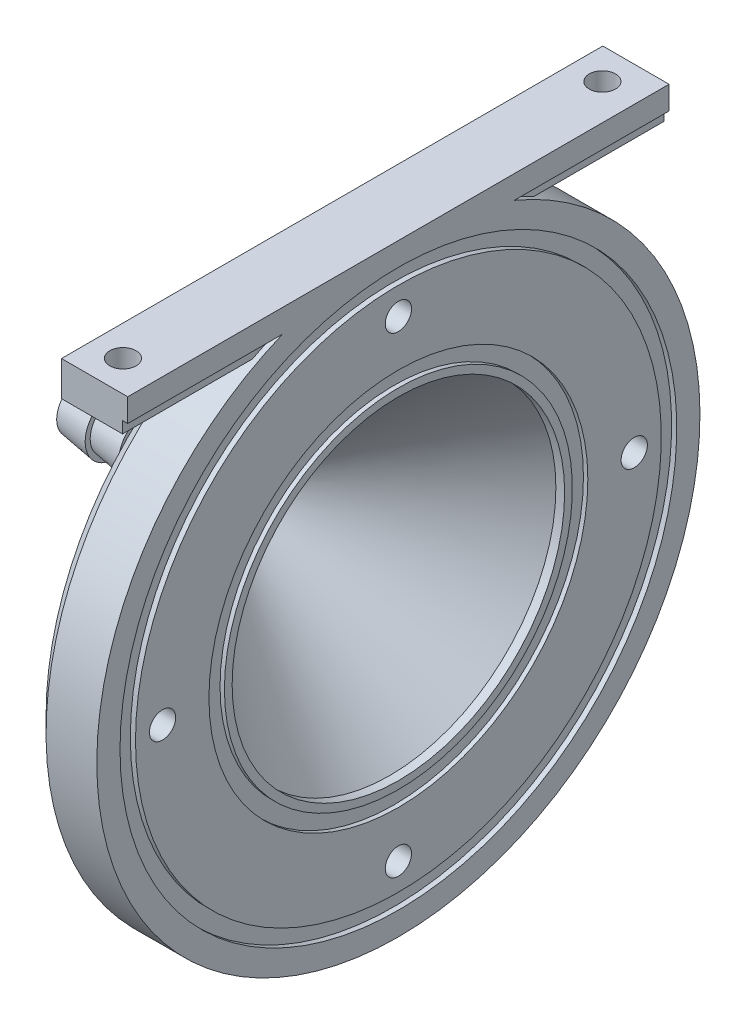
from build123d import *

# Parameters (mm, degrees)
SKETCH1_W                = 0.566
SKETCH1_H                = 1
M3_CLEARANCE_HOLE1_D     = 3.4
M3_CLEARANCE_HOLE1_DEPTH = 8.566
M3_CLEARANCE_HOLE1_TIP   = 1.021463052
CHAMFER1_SIZE            = 2
BOSS_EXTRUDE1_DEPTH      = 35
SKETCH9_R                = 1.7
CUT_EXTRUDE1_DEPTH       = 10


with BuildPart() as part:
    # Sketch1 → Revolve17 (revolve)
    with BuildSketch(Plane.XY, mode=Mode.PRIVATE) as revolve17_sk:
        Polygon((14.13111535, 39), (14.13111535, 34.5), (22.03011535, 34.5), (22.03011535, 36), (22.69711535, 36), (22.69711535, 39), align=None)
        Polygon((-14.010170791, 3.15), (-14.010170791, 3.8), (-18.343504124, 3.15), (-18.343504124, 1.9), (0, 1.9), (21.56511535, 21.5), (22.13111535, 21.5), (22.13111535, 22.5), (22.13111535, 24.5), (22.69711535, 24.5), (22.69711535, 34), (22.03011535, 34), (22.03011535, 34.5), (14.13111535, 34.5), (14.13111535, 21.5), (-5.343504124, 3.8), (-9.676837458, 3.15), (-9.676837458, 3.8), align=None)
        with Locations((22.41411535, 22)):
            Rectangle(SKETCH1_W, SKETCH1_H)
    revolve(revolve17_sk.sketch.rotate(Axis((-801.927103621, 0, 0), (1, 0, 0)), 90), axis=Axis((-801.927103621, 0, 0), (1, 0, 0)))

    # M3 Clearance Hole1
    with Locations(Plane.ZY.offset(-14.13111535)):
        with Locations((0, -30.5), (0, 30.5), (30.5, 0), (-30.5, 0)):
            Hole(M3_CLEARANCE_HOLE1_D / 2, depth=M3_CLEARANCE_HOLE1_DEPTH)
            with Locations((0, 0, -(M3_CLEARANCE_HOLE1_DEPTH + M3_CLEARANCE_HOLE1_TIP / 2))):  # 118° drill point
                Cone(0, M3_CLEARANCE_HOLE1_D / 2, M3_CLEARANCE_HOLE1_TIP, mode=Mode.SUBTRACT)

    # Chamfer1
    chamfer1_edges = [part.edges().sort_by_distance(p)[0] for p in [
        (14.13111535, 0, -39),
    ]]
    chamfer(chamfer1_edges, length=CHAMFER1_SIZE)

    # Sketch1_11 → Boss-Extrude1 (add, symmetric)
    with BuildSketch(Plane.XY):
        Polygon((14.13111535, 39), (14.13111535, 34.5), (22.03011535, 34.5), (22.03011535, 36), (22.69711535, 36), (22.69711535, 39), align=None)
    extrude(amount=BOSS_EXTRUDE1_DEPTH, both=True)

    # Sketch9 → Cut-Extrude1 (cut)
    with BuildSketch(Plane(origin=(0, 34.5, 0), x_dir=(-1, 0, 0), z_dir=(0, -1, 0))):
        with Locations(Location((-18.08061535, -31, 0), (0, 0, 90))):
            Circle(SKETCH9_R)
        with Locations((-18.08061535, 31)):
            Circle(SKETCH9_R)
    extrude(amount=-CUT_EXTRUDE1_DEPTH, mode=Mode.SUBTRACT)


solid = part.part
